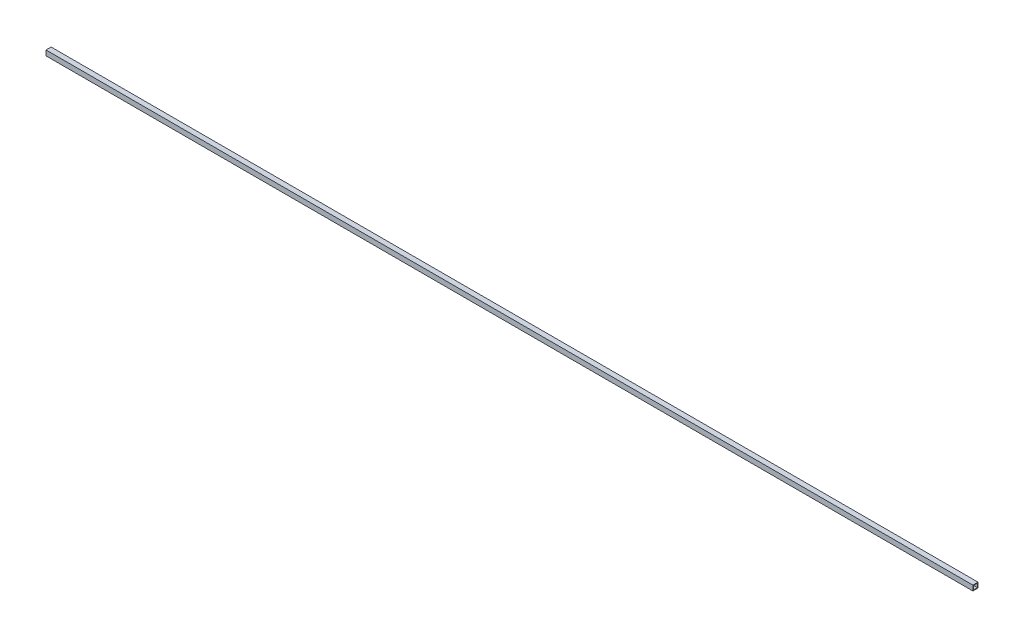
from build123d import *

# Parameters (mm, degrees)
SKETCH11_W                                     = 50.8
SKETCH11_H                                     = 50.8
SKETCH11_W_2                                   = 38.1
SKETCH11_H_2                                   = 38.1
AL_TUBE_SQUARE_AL_TUBE_2_SQR_X_0_25_WALL_DEPTH = 9193.53


with BuildPart() as part:
    # Sketch11 → Al tube square AL TUBE 2 SQR X 0.25 WALL(1) (new body)
    with BuildSketch(Plane.YZ):
        Rectangle(SKETCH11_W, SKETCH11_H)
        Rectangle(SKETCH11_W_2, SKETCH11_H_2, mode=Mode.SUBTRACT)
    extrude(amount=AL_TUBE_SQUARE_AL_TUBE_2_SQR_X_0_25_WALL_DEPTH)


solid = part.part
